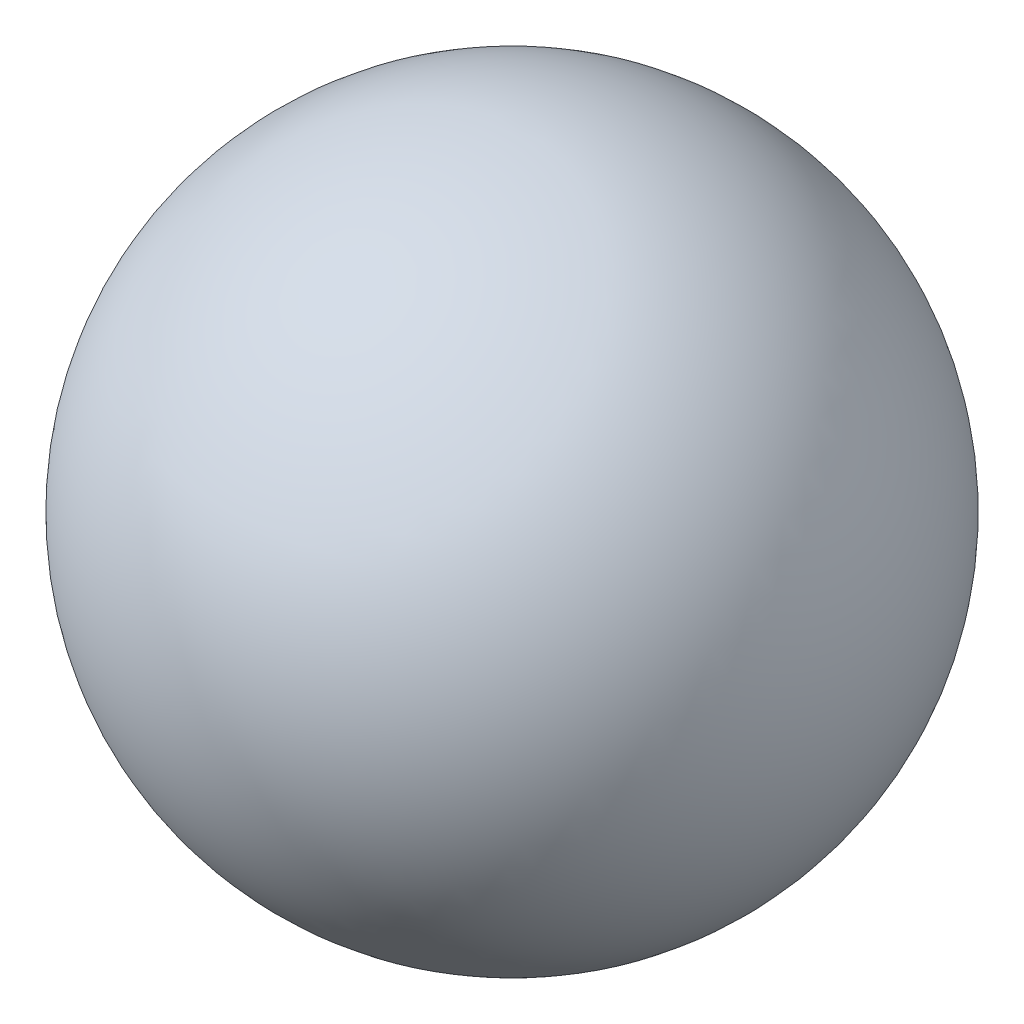
from build123d import *


with BuildPart() as part:
    # Sketch1 one side → Revolve7 (revolve)
    with BuildSketch(Plane.XY):
        with BuildLine():
            ThreePointArc((0, -9.525), (6.735192091, -6.735192091), (9.525, 0))
            ThreePointArc((9.525, 0), (6.735192091, 6.735192091), (0, 9.525))
            Line((0, 9.525), (0, -9.525))
        make_face()
    revolve(axis=Axis((0, 9.525, 0), (0, -1, 0)))


solid = part.part
